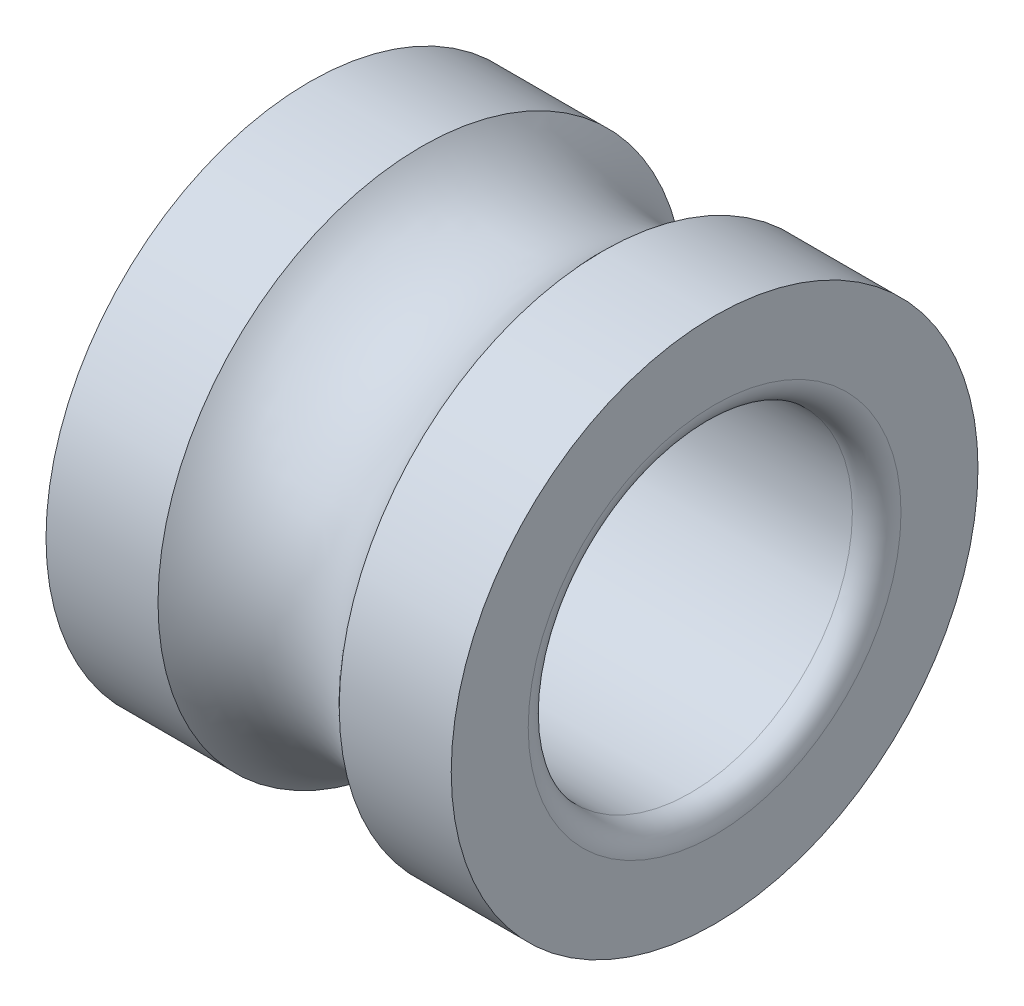
from build123d import *

# Parameters (mm, degrees)
CONG_1_R = 0.3


with BuildPart() as part:
    # Esquisse1 → Base-Révolution (revolve)
    with BuildSketch(Plane.XY):
        with BuildLine():
            Line((3.618033989, 3.25), (5, 3.25))
            Line((5, 3.25), (5, 2))
            Line((5, 2), (0, 2))
            Line((0, 2), (0, 3.25))
            Line((0, 3.25), (1.381966011, 3.25))
            ThreePointArc((1.381966011, 3.25), (2.5, 2.75), (3.618033989, 3.25))
        make_face()
    revolve(axis=Axis((0, 0, 0), (1, 0, 0)))

    # Congé1
    cong_1_edges = [part.edges().sort_by_distance(p)[0] for p in [
        (5, -2, 0),
        (0, -2, 0),
    ]]
    fillet(cong_1_edges, radius=CONG_1_R)


solid = part.part
